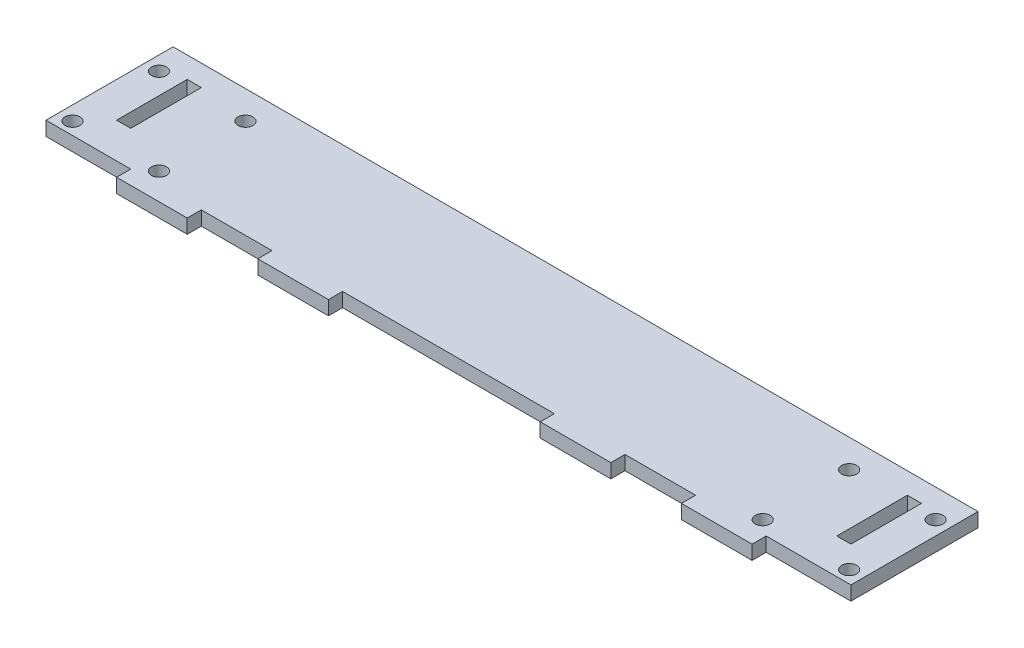
from build123d import *

# Parameters (mm, degrees)
SKETCH1_R           = 2.125
SKETCH1_W           = 4
SKETCH1_H           = 20
BOSS_EXTRUDE2_DEPTH = 4


with BuildPart() as part:
    # Sketch1 → Boss-Extrude2 (new body)
    with BuildSketch(Plane(origin=(0, 0, 0), x_dir=(1, 0, 0), z_dir=(0, 1, 0))):
        Polygon((64, 0), (64, -4), (84, -4), (84, 0), (144, 0), (144, -4), (164, -4), (164, 0), (184, 0), (184, -4), (204, -4), (204, 0), (228, 0), (228, 36), (0, 36), (0, 0), (24, 0), (24, -4), (44, -4), (44, 0), align=None)
        with Locations((4, 3.5)):
            Circle(SKETCH1_R, mode=Mode.SUBTRACT)
        with Locations((28.5, 3.5)):
            Circle(SKETCH1_R, mode=Mode.SUBTRACT)
        with Locations((199.5, 3.5)):
            Circle(SKETCH1_R, mode=Mode.SUBTRACT)
        with Locations((224, 3.5)):
            Circle(SKETCH1_R, mode=Mode.SUBTRACT)
        with Locations((12, 20)):
            Rectangle(SKETCH1_W, SKETCH1_H, mode=Mode.SUBTRACT)
        with Locations((4, 28)):
            Circle(SKETCH1_R, mode=Mode.SUBTRACT)
        with Locations((28.5, 28)):
            Circle(SKETCH1_R, mode=Mode.SUBTRACT)
        with Locations((216, 20)):
            Rectangle(SKETCH1_W, SKETCH1_H, mode=Mode.SUBTRACT)
        with Locations((199.5, 28)):
            Circle(SKETCH1_R, mode=Mode.SUBTRACT)
        with Locations((224, 28)):
            Circle(SKETCH1_R, mode=Mode.SUBTRACT)
    extrude(amount=BOSS_EXTRUDE2_DEPTH)


solid = part.part
